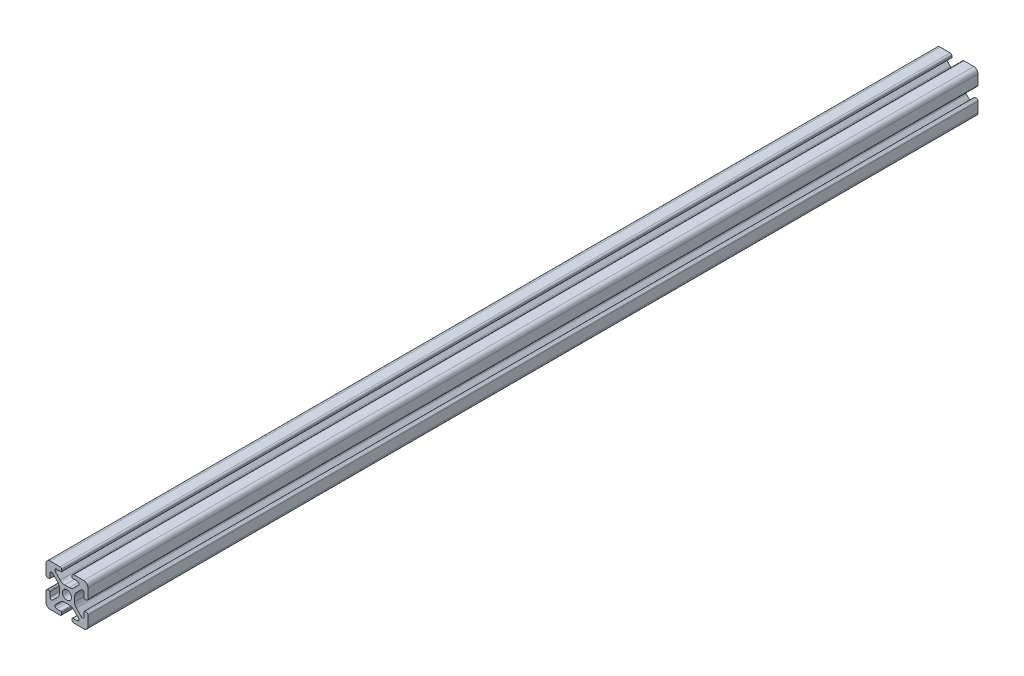
from build123d import *

# Parameters (mm, degrees)
SKETCH3_R                = 2.15
BOSS_EXTRUDE1_DEPTH      = 212.5
BOSS_EXTRUDE1_DEPTH_BACK = 212.5


with BuildPart() as part:
    # Sketch3 → Boss-Extrude1 (new body, two sides)
    with BuildSketch(Plane.XY) as boss_extrude1_sk:
        with BuildLine():
            Line((3.2874, 10), (8, 10))
            ThreePointArc((8, 10), (9.414213562, 9.414213562), (10, 8))
            Line((10, 8), (10, 3.2874))
            ThreePointArc((10, 3.2874), (9.76937588, 2.73062412), (9.2126, 2.5))
            Line((9.2126, 2.5), (8.5048, 2.5))
            ThreePointArc((8.5048, 2.5), (8.289273853, 2.589273853), (8.2, 2.8048))
            Line((8.2, 2.8048), (8.2, 4.9118))
            ThreePointArc((8.2, 4.9118), (7.682565253, 5.686195824), (6.769103096, 5.504496904))
            Line((6.769103096, 5.504496904), (4.478679656, 3.214073464))
            ThreePointArc((4.478679656, 3.214073464), (3.828361402, 2.240803418), (3.6, 1.092753121))
            Line((3.6, 1.092753121), (3.6, -1.092753121))
            ThreePointArc((3.6, -1.092753121), (3.828361402, -2.240803418), (4.478679656, -3.214073464))
            Line((4.478679656, -3.214073464), (6.769103096, -5.504496904))
            ThreePointArc((6.769103096, -5.504496904), (7.682565253, -5.686195824), (8.2, -4.9118))
            Line((8.2, -4.9118), (8.2, -2.8048))
            ThreePointArc((8.2, -2.8048), (8.289273853, -2.589273853), (8.5048, -2.5))
            Line((8.5048, -2.5), (9.2126, -2.5))
            ThreePointArc((9.2126, -2.5), (9.76937588, -2.73062412), (10, -3.2874))
            Line((10, -3.2874), (10, -8))
            ThreePointArc((10, -8), (9.414213562, -9.414213562), (8, -10))
            Line((8, -10), (3.2874, -10))
            ThreePointArc((3.2874, -10), (2.73062412, -9.76937588), (2.5, -9.2126))
            Line((2.5, -9.2126), (2.5, -8.5048))
            ThreePointArc((2.5, -8.5048), (2.589273853, -8.289273853), (2.8048, -8.2))
            Line((2.8048, -8.2), (4.9118, -8.2))
            ThreePointArc((4.9118, -8.2), (5.686195824, -7.682565253), (5.504496904, -6.769103096))
            Line((5.504496904, -6.769103096), (3.214073464, -4.478679656))
            ThreePointArc((3.214073464, -4.478679656), (2.240803418, -3.828361402), (1.092753121, -3.6))
            Line((1.092753121, -3.6), (-1.092753121, -3.6))
            ThreePointArc((-1.092753121, -3.6), (-2.240803418, -3.828361402), (-3.214073464, -4.478679656))
            Line((-3.214073464, -4.478679656), (-5.504496904, -6.769103096))
            ThreePointArc((-5.504496904, -6.769103096), (-5.686195824, -7.682565253), (-4.9118, -8.2))
            Line((-4.9118, -8.2), (-2.8048, -8.2))
            ThreePointArc((-2.8048, -8.2), (-2.589273853, -8.289273853), (-2.5, -8.5048))
            Line((-2.5, -8.5048), (-2.5, -9.2126))
            ThreePointArc((-2.5, -9.2126), (-2.73062412, -9.76937588), (-3.2874, -10))
            Line((-3.2874, -10), (-8, -10))
            ThreePointArc((-8, -10), (-9.414213562, -9.414213562), (-10, -8))
            Line((-10, -8), (-10, -3.2874))
            ThreePointArc((-10, -3.2874), (-9.76937588, -2.73062412), (-9.2126, -2.5))
            Line((-9.2126, -2.5), (-8.5048, -2.5))
            ThreePointArc((-8.5048, -2.5), (-8.289273853, -2.589273853), (-8.2, -2.8048))
            Line((-8.2, -2.8048), (-8.2, -4.9118))
            ThreePointArc((-8.2, -4.9118), (-7.682565253, -5.686195824), (-6.769103096, -5.504496904))
            Line((-6.769103096, -5.504496904), (-4.478679656, -3.214073464))
            ThreePointArc((-4.478679656, -3.214073464), (-3.828361402, -2.240803418), (-3.6, -1.092753121))
            Line((-3.6, -1.092753121), (-3.6, 1.092753121))
            ThreePointArc((-3.6, 1.092753121), (-3.828361402, 2.240803418), (-4.478679656, 3.214073464))
            Line((-4.478679656, 3.214073464), (-6.769103096, 5.504496904))
            ThreePointArc((-6.769103096, 5.504496904), (-7.682565253, 5.686195824), (-8.2, 4.9118))
            Line((-8.2, 4.9118), (-8.2, 2.8048))
            ThreePointArc((-8.2, 2.8048), (-8.289273853, 2.589273853), (-8.5048, 2.5))
            Line((-8.5048, 2.5), (-9.2126, 2.5))
            ThreePointArc((-9.2126, 2.5), (-9.76937588, 2.73062412), (-10, 3.2874))
            Line((-10, 3.2874), (-10, 8))
            ThreePointArc((-10, 8), (-9.414213562, 9.414213562), (-8, 10))
            Line((-8, 10), (-3.2874, 10))
            ThreePointArc((-3.2874, 10), (-2.73062412, 9.76937588), (-2.5, 9.2126))
            Line((-2.5, 9.2126), (-2.5, 8.5048))
            ThreePointArc((-2.5, 8.5048), (-2.589273853, 8.289273853), (-2.8048, 8.2))
            Line((-2.8048, 8.2), (-4.9118, 8.2))
            ThreePointArc((-4.9118, 8.2), (-5.686195824, 7.682565253), (-5.504496904, 6.769103096))
            Line((-5.504496904, 6.769103096), (-3.214073464, 4.478679656))
            ThreePointArc((-3.214073464, 4.478679656), (-2.240803418, 3.828361402), (-1.092753121, 3.6))
            Line((-1.092753121, 3.6), (1.092753121, 3.6))
            ThreePointArc((1.092753121, 3.6), (2.240803418, 3.828361402), (3.214073464, 4.478679656))
            Line((3.214073464, 4.478679656), (5.504496904, 6.769103096))
            ThreePointArc((5.504496904, 6.769103096), (5.686195824, 7.682565253), (4.9118, 8.2))
            Line((4.9118, 8.2), (2.8048, 8.2))
            ThreePointArc((2.8048, 8.2), (2.589273853, 8.289273853), (2.5, 8.5048))
            Line((2.5, 8.5048), (2.5, 9.2126))
            ThreePointArc((2.5, 9.2126), (2.73062412, 9.76937588), (3.2874, 10))
        make_face()
        Circle(SKETCH3_R, mode=Mode.SUBTRACT)
    extrude(amount=BOSS_EXTRUDE1_DEPTH)
    extrude(boss_extrude1_sk.sketch, amount=-BOSS_EXTRUDE1_DEPTH_BACK)


solid = part.part
